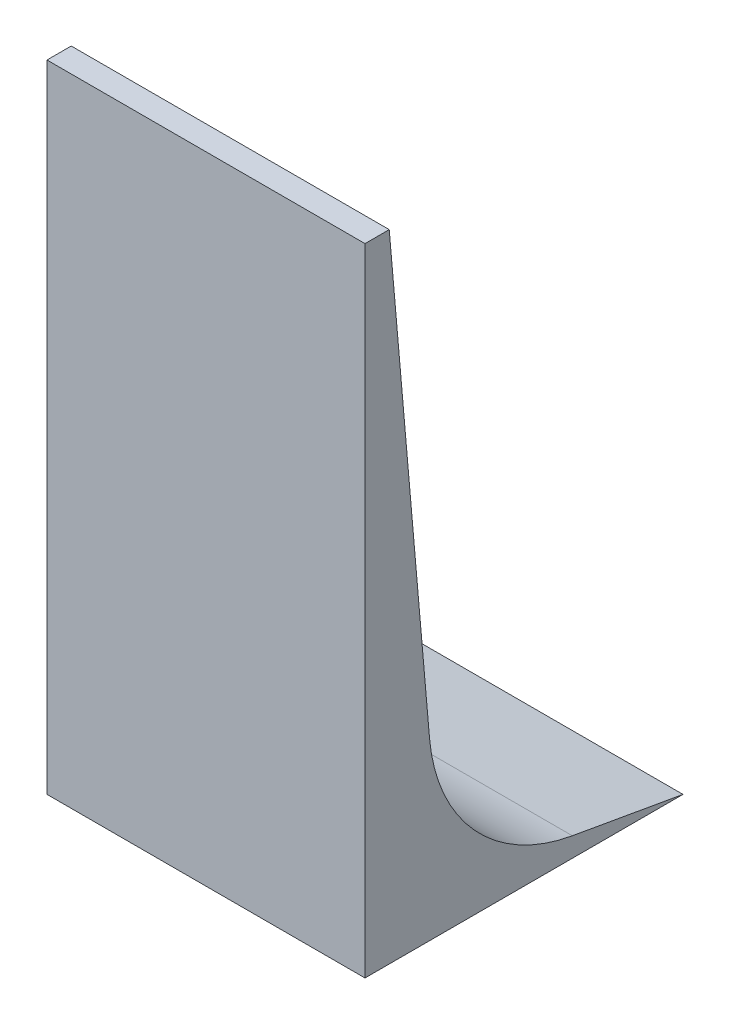
from build123d import *

# Parameters (mm, degrees)
BOSS_EXTRUDE1_DEPTH = 500


with BuildPart() as part:
    # Sketch1 → Boss-Extrude1 (new body)
    with BuildSketch(Plane(origin=(0, 0, 0), x_dir=(0, 0, -1), z_dir=(1, 0, 0))):
        with BuildLine():
            Line((38.1, 1000), (101.4671252, 275.710444691))
            ThreePointArc((101.4671252, 275.710444691), (172.142788026, 115.087782586), (325.99444252, 30.681874577))
            Line((325.99444252, 30.681874577), (500, 0))
            Line((500, 0), (0, 0))
            Line((0, 0), (0, 1000))
            Line((0, 1000), (38.1, 1000))
        make_face()
    extrude(amount=-BOSS_EXTRUDE1_DEPTH)


solid = part.part
